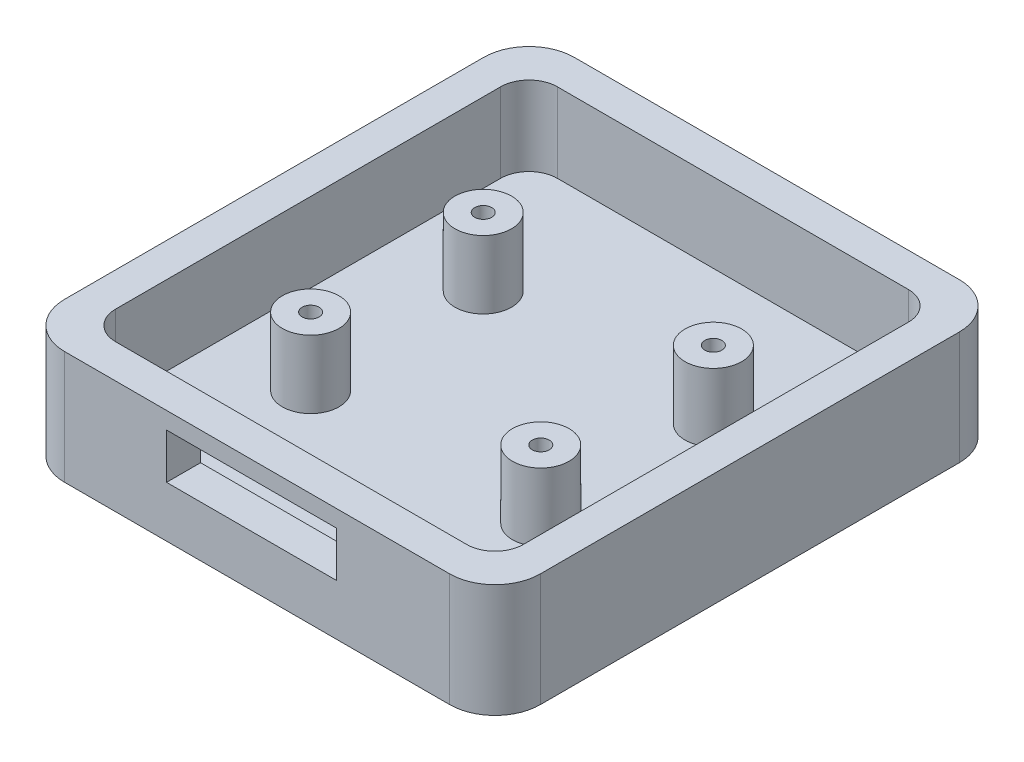
from build123d import *

# Parameters (mm, degrees)
SKETCH1_W           = 42
SKETCH1_H           = 45
SKETCH1_W_2         = 36
SKETCH1_H_2         = 39
BOSS_EXTRUDE1_DEPTH = 10
SKETCH2_W           = 36
SKETCH2_H           = 39
BOSS_EXTRUDE2_DEPTH = 3
FILLET1_R           = 4
SKETCH3_R           = 2.5
BOSS_EXTRUDE3_DEPTH = 6
SKETCH4_R           = 0.75
CUT_EXTRUDE1_DEPTH  = 5
SKETCH5_W           = 15
SKETCH5_H           = 4
CUT_EXTRUDE2_DEPTH  = 15
CUT_EXTRUDE3_DEPTH  = 0.2
FILLET2_R           = 2.5


with BuildPart() as part:
    # Sketch1 → Boss-Extrude1 (new body)
    with BuildSketch(Plane(origin=(0, 0, 0), x_dir=(1, 0, 0), z_dir=(0, 1, 0))):
        Rectangle(SKETCH1_W, SKETCH1_H)
        Rectangle(SKETCH1_W_2, SKETCH1_H_2, mode=Mode.SUBTRACT)
    extrude(amount=BOSS_EXTRUDE1_DEPTH)

    # Sketch2 → Boss-Extrude2 (add)
    with BuildSketch(Plane.XZ):
        Rectangle(SKETCH2_W, SKETCH2_H)
    extrude(amount=-BOSS_EXTRUDE2_DEPTH)

    # Fillet1
    fillet1_edges = [part.edges().sort_by_distance(p)[0] for p in [
        (-21, 5, -22.5),
        (21, 5, -22.5),
        (21, 5, 22.5),
        (-21, 5, 22.5),
    ]]
    fillet(fillet1_edges, radius=FILLET1_R)

    # Sketch3 → Boss-Extrude3 (add)
    with BuildSketch(Plane(origin=(0, 3, 0), x_dir=(1, 0, 0), z_dir=(0, 1, 0))):
        with Locations(Location((-10.16, 7.62, 0), (0, 0, 90))):
            Circle(SKETCH3_R)
        with Locations(Location((10.16, 7.62, 0), (0, 0, 90))):
            Circle(SKETCH3_R)
        with Locations(Location((-10.16, -7.62, 0), (0, 0, 90))):
            Circle(SKETCH3_R)
        with Locations(Location((10.16, -7.62, 0), (0, 0, 90))):
            Circle(SKETCH3_R)
    extrude(amount=BOSS_EXTRUDE3_DEPTH)

    # Sketch4 → Cut-Extrude1 (cut)
    with BuildSketch(Plane(origin=(0, 9, 0), x_dir=(1, 0, 0), z_dir=(0, 1, 0))):
        with Locations(Location((-10.16, 7.62, 0), (0, 0, 270))):
            Circle(SKETCH4_R)
        with Locations(Location((-10.16, -7.62, 0), (0, 0, 270))):
            Circle(SKETCH4_R)
        with Locations(Location((10.16, -7.62, 0), (0, 0, 270))):
            Circle(SKETCH4_R)
        with Locations(Location((10.16, 7.62, 0), (0, 0, 270))):
            Circle(SKETCH4_R)
    extrude(amount=-CUT_EXTRUDE1_DEPTH, mode=Mode.SUBTRACT)

    # Sketch5 → Cut-Extrude2 (cut)
    with BuildSketch(Plane(origin=(0, 0, 19.5), x_dir=(-1, 0, 0), z_dir=(0, 0, -1))):
        with Locations((0.5, 6.5)):
            Rectangle(SKETCH5_W, SKETCH5_H)
    extrude(amount=-CUT_EXTRUDE2_DEPTH, mode=Mode.SUBTRACT)

    # Sketch6 → Cut-Extrude3 (cut)
    with BuildSketch(Plane.ZY.offset(21)):
        Polygon((-7.266721491, 2.712388765), (-6.990405702, 3.510634379), (-9.507949561, 3.510634379), (-9.285361842, 4.153452362), (-5.994517544, 6.273792274), (-5.112801535, 6.273792274), (-5.835252193, 4.186072976), (-5.037006579, 4.186072976), (-5.271107456, 3.510634379), (-6.06935307, 3.510634379), (-6.34566886, 2.712388765), align=None)
        Polygon((-6.756304825, 4.186072976), (-6.280427632, 5.561895344), (-8.388294956, 4.186072976), align=None, mode=Mode.SUBTRACT)
        with BuildLine():
            add(Edge.make_bspline(
                [(-3.622807018, 5.434291178), (-3.609125703, 5.472498738), (-3.582545271, 5.54672943), (-3.537483971, 5.652157352), (-3.489800408, 5.74850445), (-3.438522606, 5.834974529), (-3.386287317, 5.913277571), (-3.330199696, 5.981839438), (-3.27195556, 6.041513714), (-3.209996228, 6.092811414), (-3.143184007, 6.13653488), (-3.069071262, 6.17283863), (-2.988059664, 6.20483325), (-2.899371495, 6.230350278), (-2.802984993, 6.249226914), (-2.699554313, 6.26362571), (-2.588367112, 6.272232809), (-2.511802499, 6.27326286), (-2.472450658, 6.273792274)],
                knots=[0, 0, 0, 0, 1.249331581, 2.427235558, 3.528166943, 4.556651363, 5.520755527, 6.423519263, 7.279984445, 8.084372863, 8.895543411, 9.732251264, 10.620942281, 11.574529366, 12.569079362, 13.642766893, 14.788455148, 16, 16, 16, 16], degree=3))
            Line((-2.472450658, 6.273792274), (-0.261924342, 6.273792274))
            add(Edge.make_bspline(
                [(-0.261924342, 6.273792274), (-0.219698753, 6.273259731), (-0.139307296, 6.272245846), (-0.025113505, 6.264200241), (0.076487294, 6.24870724), (0.165710312, 6.228464159), (0.242614677, 6.201373731), (0.307906709, 6.169690821), (0.360046195, 6.129734961), (0.399858565, 6.083238358), (0.428541631, 6.02954479), (0.446165744, 5.968104442), (0.455593104, 5.898986605), (0.455919976, 5.821726589), (0.44821628, 5.736218267), (0.429940141, 5.642776027), (0.404284779, 5.540705956), (0.380764616, 5.470916974), (0.368421053, 5.434291178)],
                knots=[0, 0, 0, 0, 1.469254432, 2.797249418, 3.979160335, 5.042611798, 5.975294901, 6.811365435, 7.557013877, 8.243791966, 8.925866039, 9.658108473, 10.455983269, 11.346280162, 12.340651059, 13.438479066, 14.655694067, 16, 16, 16, 16], degree=3))
            Line((0.368421053, 5.434291178), (-0.252330044, 3.642076265))
            add(Edge.make_bspline(
                [(-0.252330044, 3.642076265), (-0.265937591, 3.603840041), (-0.292417224, 3.529434184), (-0.338720334, 3.423892101), (-0.387819317, 3.327103141), (-0.438050989, 3.237585926), (-0.494152591, 3.158541905), (-0.551548956, 3.086810915), (-0.612268233, 3.023827739), (-0.677306637, 2.969076408), (-0.748745086, 2.92264188), (-0.827123423, 2.881565266), (-0.914762349, 2.848929718), (-1.010163075, 2.820629592), (-1.114298793, 2.80009922), (-1.226439542, 2.785031692), (-1.347179136, 2.774999128), (-1.430488587, 2.774204359), (-1.473684211, 2.773792274)],
                knots=[0, 0, 0, 0, 1.188107917, 2.312000937, 3.371553067, 4.365820401, 5.314039932, 6.206175103, 7.053854051, 7.871571644, 8.689718091, 9.544146222, 10.457170493, 11.42321035, 12.455343696, 13.561184669, 14.735483814, 16, 16, 16, 16], degree=3))
            Line((-1.473684211, 2.773792274), (-3.684210526, 2.773792274))
            add(Edge.make_bspline(
                [(-3.684210526, 2.773792274), (-3.722926629, 2.774289774), (-3.796945951, 2.775240919), (-3.902063124, 2.783809288), (-3.996275588, 2.797536629), (-4.078401545, 2.818632904), (-4.150111269, 2.844065177), (-4.209723679, 2.876432654), (-4.258708143, 2.914547344), (-4.296469346, 2.959821461), (-4.322945878, 3.01374343), (-4.338929141, 3.076370867), (-4.344836867, 3.148177592), (-4.342487919, 3.22885201), (-4.331575451, 3.319074109), (-4.310829762, 3.418276147), (-4.281943065, 3.527582101), (-4.256806516, 3.602559094), (-4.243558114, 3.642076265)],
                knots=[0, 0, 0, 0, 1.362778535, 2.605426016, 3.710546917, 4.710016498, 5.586353413, 6.382497134, 7.087612643, 7.75939945, 8.439158876, 9.184733762, 10.021631923, 10.967670448, 12.022072564, 13.216659621, 14.533020127, 16, 16, 16, 16], degree=3))
            Line((-4.243558114, 3.642076265), (-3.622807018, 5.434291178))
        make_face()
        Polygon((-3.367598684, 3.510634379), (-1.218475877, 3.510634379), (-0.496025219, 5.598353678), (-2.645148026, 5.598353678), align=None, mode=Mode.SUBTRACT)
        Polygon((2.333333333, 2.773792274), (3.273574561, 5.488019248), (2.536732456, 5.488019248), (2.730537281, 6.049285695), (4.466145833, 6.273792274), (3.254385965, 2.773792274), align=None)
        with BuildLine():
            add(Edge.make_bspline(
                [(9.18941886, 4.116034599), (9.139272238, 4.106699282), (9.035140113, 4.087314002), (8.871843281, 4.06481389), (8.696144139, 4.045946479), (8.445566082, 4.02419338), (8.123405142, 4.006887823), (7.863828943, 4.003538237), (7.733963816, 4.001862449)],
                knots=[0, 0, 0, 0, 0.628001545, 1.30407859, 2.029000612, 2.803721834, 4.400912441, 6, 6, 6, 6], degree=3))
            add(Edge.make_bspline(
                [(7.733963816, 4.001862449), (7.66805863, 4.002123532), (7.541910485, 4.002623266), (7.361841131, 4.014317967), (7.19922006, 4.027937024), (7.055200876, 4.051476588), (6.928253576, 4.078902561), (6.820017245, 4.115706666), (6.727864728, 4.155719103), (6.653811583, 4.205304002), (6.595779926, 4.264096978), (6.551796799, 4.33216316), (6.522900151, 4.411139689), (6.508090406, 4.499791623), (6.506463043, 4.59839082), (6.520441793, 4.706281311), (6.545071853, 4.824392108), (6.571558547, 4.90460207), (6.585526316, 4.946900827)],
                knots=[0, 0, 0, 0, 1.659662536, 3.176735622, 4.544246863, 5.767980187, 6.850603607, 7.810997522, 8.643707531, 9.374343207, 10.040832609, 10.711205449, 11.399489889, 12.143808987, 12.965654452, 13.873957027, 14.878830352, 16, 16, 16, 16], degree=3))
            Line((6.585526316, 4.946900827), (6.744791667, 5.406467713))
            add(Edge.make_bspline(
                [(6.744791667, 5.406467713), (6.758240356, 5.442548697), (6.784634681, 5.513361041), (6.834303324, 5.613580024), (6.889667775, 5.706942583), (6.952530474, 5.793130385), (7.022597535, 5.871829515), (7.099687728, 5.94319621), (7.183958881, 6.00701834), (7.275377216, 6.063460948), (7.373820873, 6.113685787), (7.479799356, 6.156753189), (7.593641035, 6.193345301), (7.714954702, 6.222477814), (7.843698565, 6.245883974), (7.979929737, 6.261384957), (8.123939179, 6.272807964), (8.222608805, 6.273458807), (8.273163377, 6.273792274)],
                knots=[0, 0, 0, 0, 0.975433872, 1.914381268, 2.830517391, 3.723884975, 4.6138258, 5.497208004, 6.382410736, 7.288921079, 8.216993288, 9.180395812, 10.185294381, 11.244998404, 12.340526172, 13.499816095, 14.719000648, 16, 16, 16, 16], degree=3))
            Line((8.273163377, 6.273792274), (9.664336623, 6.273792274))
            add(Edge.make_bspline(
                [(9.664336623, 6.273792274), (9.720962235, 6.273121199), (9.828905501, 6.271841954), (9.982414827, 6.260572195), (10.119628402, 6.241580279), (10.240808406, 6.215915343), (10.344980813, 6.180400503), (10.433531883, 6.138452124), (10.505339036, 6.087796395), (10.561867321, 6.028391156), (10.601624251, 5.958619218), (10.629927095, 5.879461242), (10.644157726, 5.789529976), (10.647897887, 5.689361447), (10.638357393, 5.578459481), (10.616927624, 5.456877982), (10.582596486, 5.32472173), (10.552969625, 5.234249411), (10.537417763, 5.186758283)],
                knots=[0, 0, 0, 0, 1.487861285, 2.836253758, 4.041378781, 5.126094178, 6.085495922, 6.927392284, 7.692327336, 8.382057701, 9.063806296, 9.786830518, 10.579870837, 11.446119896, 12.415517776, 13.498702032, 14.687007649, 16, 16, 16, 16], degree=3))
            Line((10.537417763, 5.186758283), (10.381030702, 4.735826265))
            add(Edge.make_bspline(
                [(10.381030702, 4.735826265), (10.35237135, 4.658165788), (10.295668276, 4.504513053), (10.186887701, 4.286336397), (10.062443151, 4.08083449), (9.922423928, 3.887199955), (9.764323541, 3.707080158), (9.588732014, 3.540814263), (9.397051394, 3.386994142), (9.190131799, 3.245915483), (8.968424323, 3.120777074), (8.734599098, 3.0105915), (8.488425752, 2.919226026), (8.231224131, 2.842656253), (7.961981958, 2.784843673), (7.681019409, 2.742495981), (7.38838598, 2.717452505), (7.189375469, 2.714094706), (7.088267544, 2.712388765)],
                knots=[0, 0, 0, 0, 0.959056519, 1.897511621, 2.82073509, 3.741774841, 4.663918277, 5.594873618, 6.541553392, 7.510221536, 8.494772679, 9.489898267, 10.503546759, 11.53585849, 12.598295241, 13.693093789, 14.827968931, 16, 16, 16, 16], degree=3))
            add(Edge.make_bspline(
                [(7.088267544, 2.712388765), (7.059488602, 2.712381088), (7.00960268, 2.712367781), (6.94139659, 2.712444148), (6.880665962, 2.717360835), (6.84104852, 2.720983631), (6.819627193, 2.722942493)],
                knots=[0, 0, 0, 0, 1.283807492, 2.225374378, 3.040452036, 4, 4, 4, 4], degree=3))
            Line((6.819627193, 2.722942493), (6.554824561, 3.387827362))
            Line((6.554824561, 3.387827362), (6.83785636, 3.387827362))
            add(Edge.make_bspline(
                [(6.83785636, 3.387827362), (6.921974228, 3.388344001), (7.084820205, 3.389344175), (7.320614622, 3.398005737), (7.540125394, 3.41215284), (7.743029336, 3.432063677), (7.929833408, 3.457261576), (8.099684001, 3.490222372), (8.253710221, 3.526870883), (8.392490971, 3.57030379), (8.51899634, 3.620328693), (8.637194417, 3.674562011), (8.747666259, 3.735551851), (8.851366732, 3.800150666), (8.947110779, 3.870912088), (9.035621623, 3.946566638), (9.116556619, 4.028339332), (9.165203619, 4.086889709), (9.18941886, 4.116034599)],
                knots=[0, 0, 0, 0, 1.583490646, 3.065520879, 4.441158958, 5.723748431, 6.902980015, 7.988087944, 8.97956884, 9.882119711, 10.722856289, 11.539026284, 12.328467801, 13.096828923, 13.837373089, 14.567442271, 15.286909158, 16, 16, 16, 16], degree=3))
        make_face()
        with BuildLine():
            add(Edge.make_bspline(
                [(9.457099781, 4.758852581), (9.46031833, 4.765559218), (9.469915709, 4.78555771), (9.486045334, 4.821638693), (9.504545207, 4.864171388), (9.514824175, 4.894071372), (9.519462719, 4.907564204)],
                knots=[0, 0, 0, 0, 0.553181884, 1.649530779, 2.939314314, 4, 4, 4, 4], degree=3))
            add(Edge.make_bspline(
                [(9.519462719, 4.907564204), (9.532110384, 4.945241348), (9.556123896, 5.01677713), (9.587315999, 5.118572951), (9.609168054, 5.209378955), (9.625478375, 5.287993038), (9.63304716, 5.355384945), (9.635601004, 5.411578923), (9.628262721, 5.456616984), (9.613791773, 5.492610937), (9.587644333, 5.519590765), (9.552519277, 5.540974845), (9.507443284, 5.559184643), (9.452151292, 5.572887222), (9.386728538, 5.584155909), (9.310823561, 5.592767585), (9.224328632, 5.597110555), (9.163198509, 5.597923872), (9.13089364, 5.598353678)],
                knots=[0, 0, 0, 0, 1.721404431, 3.268347822, 4.608773846, 5.765995819, 6.74189476, 7.545386644, 8.192108007, 8.706845496, 9.196952743, 9.788678392, 10.478047731, 11.294449369, 12.250887943, 13.352214739, 14.60074952, 16, 16, 16, 16], degree=3))
            Line((9.13089364, 5.598353678), (8.217516447, 5.598353678))
            add(Edge.make_bspline(
                [(8.217516447, 5.598353678), (8.172396072, 5.597809601), (8.088984229, 5.596803792), (7.974452281, 5.58503405), (7.881026284, 5.564826278), (7.804870211, 5.535331932), (7.743298089, 5.487341695), (7.690612447, 5.42124292), (7.64406824, 5.333933509), (7.618976351, 5.267691927), (7.605400219, 5.231851485)],
                knots=[0, 0, 0, 0, 1.37324589, 2.538652839, 3.497480104, 4.278561443, 5.000952917, 5.8448512, 6.833942622, 8, 8, 8, 8], degree=3))
            Line((7.605400219, 5.231851485), (7.539199561, 5.040924949))
            add(Edge.make_bspline(
                [(7.539199561, 5.040924949), (7.533197696, 5.022447812), (7.521802548, 4.9873671), (7.509444918, 4.936682577), (7.501154986, 4.891262789), (7.498643051, 4.850842873), (7.502966621, 4.81577054), (7.509633171, 4.785293092), (7.523712051, 4.760059647), (7.544047168, 4.740005944), (7.571971676, 4.723839018), (7.608909046, 4.712868888), (7.654396933, 4.700439483), (7.71022496, 4.693206405), (7.775334439, 4.684771199), (7.850657629, 4.680739694), (7.9354169, 4.677747582), (7.995244242, 4.677454567), (8.026589912, 4.677301046)],
                knots=[0, 0, 0, 0, 1.153128586, 2.189331069, 3.094609139, 3.893014441, 4.580793898, 5.188710795, 5.732779644, 6.269845169, 6.865782234, 7.628386913, 8.549458203, 9.663950049, 10.964048029, 12.448162312, 14.139066017, 16, 16, 16, 16], degree=3))
            add(Edge.make_bspline(
                [(8.026589912, 4.677301046), (8.138539914, 4.678214918), (8.368935575, 4.680095687), (8.722124946, 4.696339868), (9.087187687, 4.721493345), (9.333390916, 4.746358616), (9.457099781, 4.758852581)],
                knots=[0, 0, 0, 0, 0.937118153, 1.928610579, 2.959196292, 4, 4, 4, 4], degree=3))
        make_face(mode=Mode.SUBTRACT)
    extrude(amount=-CUT_EXTRUDE3_DEPTH, mode=Mode.SUBTRACT)

    # Fillet2
    fillet2_edges = [part.edges().sort_by_distance(p)[0] for p in [
        (18, 6.5, 19.5),
        (18, 6.5, -19.5),
        (-18, 6.5, -19.5),
        (-18, 6.5, 19.5),
    ]]
    fillet(fillet2_edges, radius=FILLET2_R)


solid = part.part
